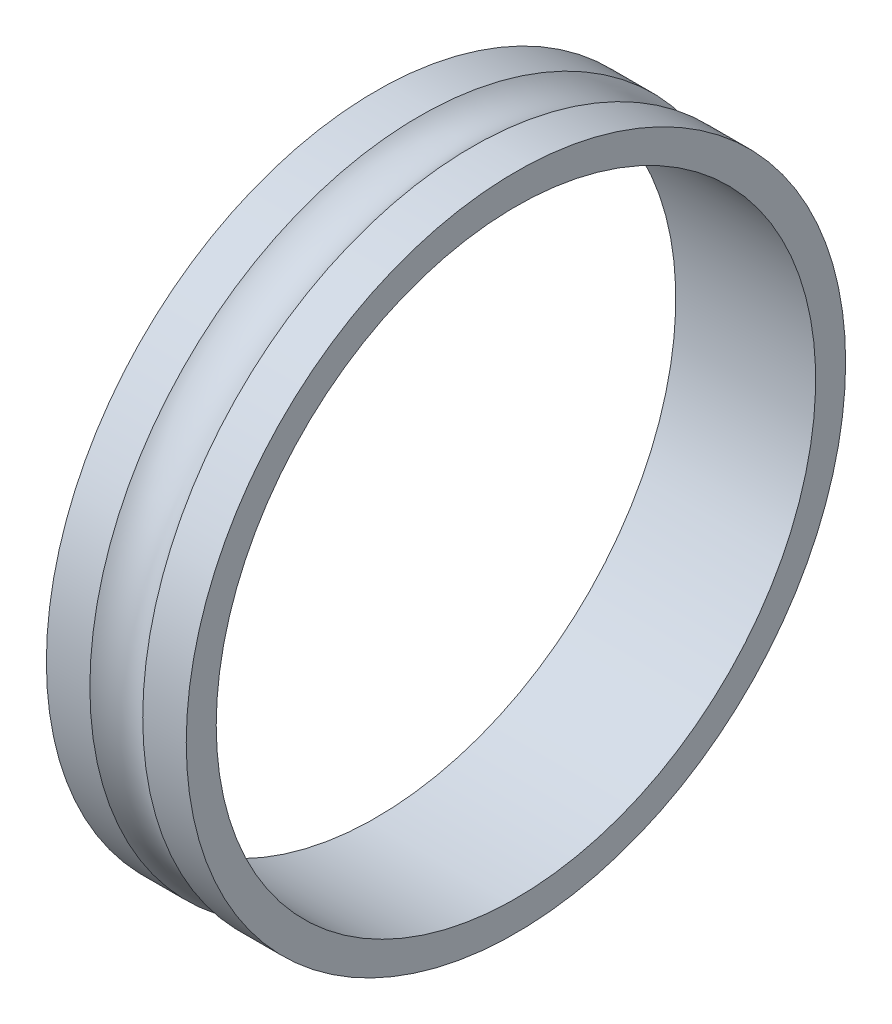
from build123d import *


with BuildPart() as part:
    # 草图1 → 旋转1 (revolve)
    with BuildSketch(Plane(origin=(0, 0, 0), x_dir=(1, 0, 0), z_dir=(0, 1, 0))):
        with BuildLine():
            Line((1.322875656, 1.5), (3.5, 1.5))
            Line((3.5, 1.5), (3.5, 3))
            Line((3.5, 3), (-3.5, 3))
            Line((-3.5, 3), (-3.5, 1.5))
            Line((-3.5, 1.5), (-1.322875656, 1.5))
            ThreePointArc((-1.322875656, 1.5), (0, 2), (1.322875656, 1.5))
        make_face()
    revolve(axis=Axis((0, 0, -18), (1, 0, 0)))


solid = part.part
